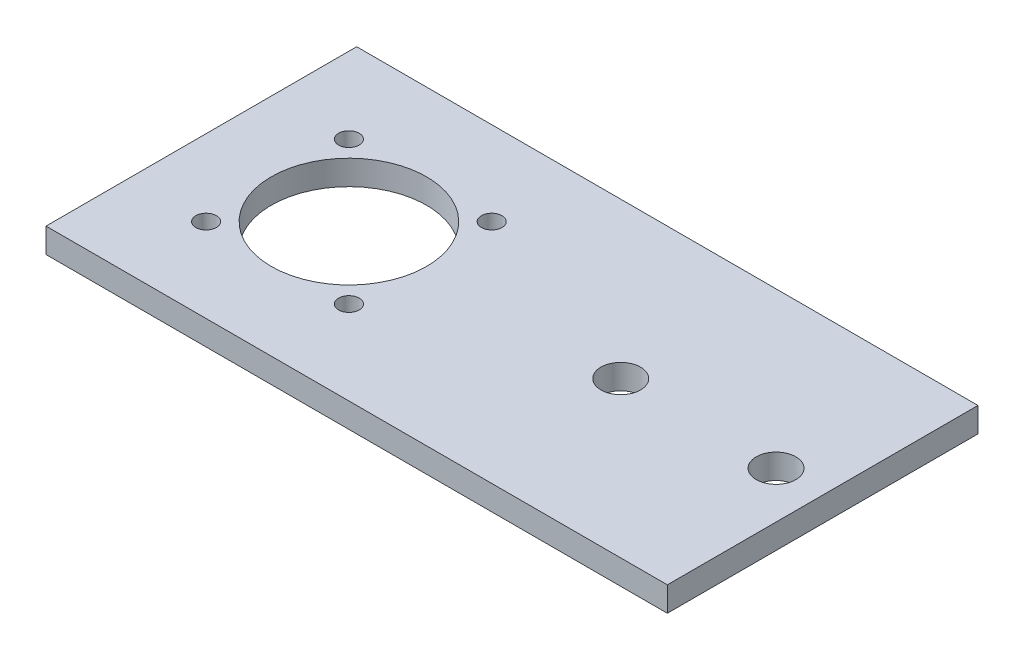
from build123d import *

# Parameters (mm, degrees)
SKETCH1_W           = 80
SKETCH1_H           = 40
SKETCH1_R           = 2.55
SKETCH1_R_2         = 10
SKETCH1_R_3         = 1.325
BOSS_EXTRUDE1_DEPTH = 3.175


with BuildPart() as part:
    # Sketch1 → Boss-Extrude1 (new body)
    with BuildSketch(Plane(origin=(0, 0, 0), x_dir=(1, 0, 0), z_dir=(0, 1, 0))):
        with Locations((40, 20)):
            Rectangle(SKETCH1_W, SKETCH1_H)
        with Locations((54, 20)):
            Circle(SKETCH1_R, mode=Mode.SUBTRACT)
        with Locations((74, 20)):
            Circle(SKETCH1_R, mode=Mode.SUBTRACT)
        with Locations((19, 20)):
            Circle(SKETCH1_R_2, mode=Mode.SUBTRACT)
        with Locations((28.192388155, 10.807611845)):
            Circle(SKETCH1_R_3, mode=Mode.SUBTRACT)
        with Locations((9.807611845, 10.807611845)):
            Circle(SKETCH1_R_3, mode=Mode.SUBTRACT)
        with Locations((9.807611845, 29.192388155)):
            Circle(SKETCH1_R_3, mode=Mode.SUBTRACT)
        with Locations((28.192388155, 29.192388155)):
            Circle(SKETCH1_R_3, mode=Mode.SUBTRACT)
    extrude(amount=BOSS_EXTRUDE1_DEPTH)


solid = part.part
